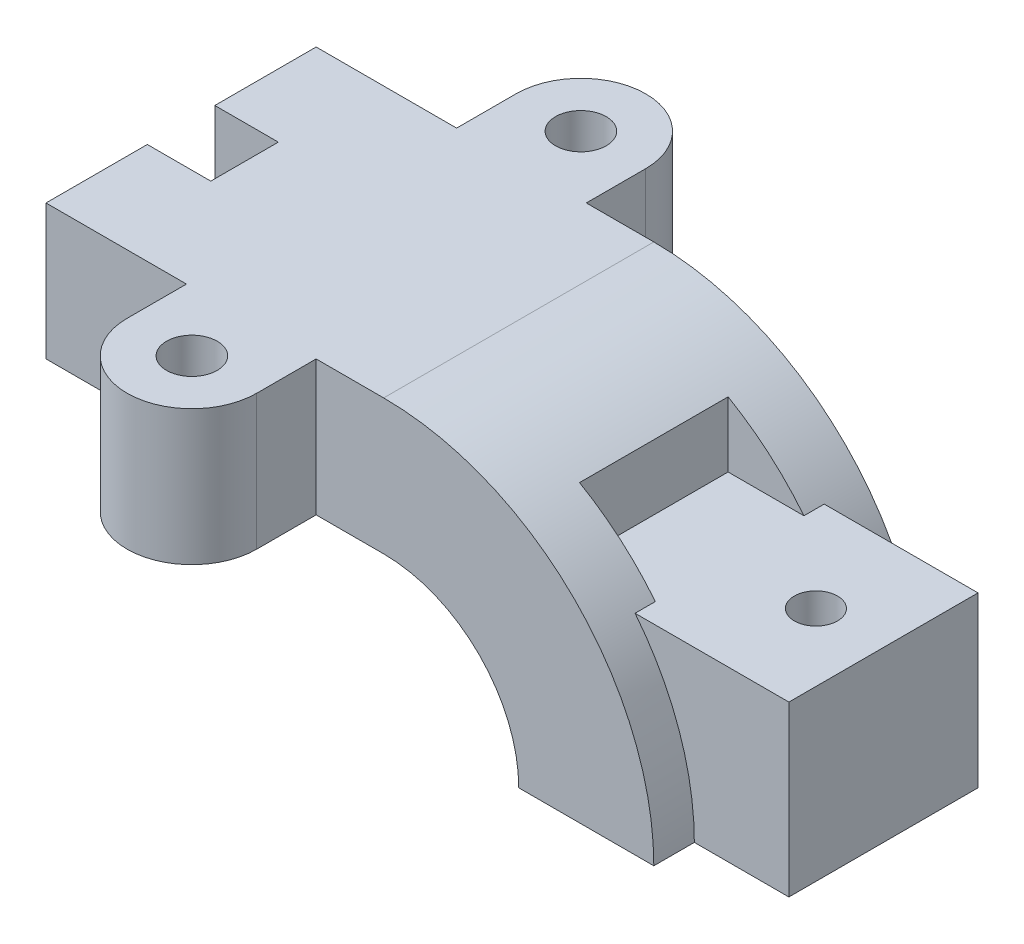
from build123d import *

# Parameters (mm, degrees)
BOSS_EXTRUDE1_DEPTH = 6.35
BOSS_EXTRUDE2_START = 6.35
SKETCH1_3_W         = 11.938
SKETCH1_3_H         = 19.05
SKETCH1_3_H_2       = 6.35
BOSS_EXTRUDE2_DEPTH = 7.62
BOSS_EXTRUDE3_START = 13.97
SKETCH1_7_W         = 11.938
SKETCH1_7_H         = 19.05
SKETCH1_7_H_2       = 6.35
BOSS_EXTRUDE3_DEPTH = 3.81
BOSS_EXTRUDE4_START = 17.78
SKETCH1_10_W        = 11.938
SKETCH1_10_H        = 6.35
SKETCH1_10_H_2      = 19.05
BOSS_EXTRUDE4_DEPTH = 7.62
SKETCH2_R           = 4.7625
BOSS_EXTRUDE5_DEPTH = 25.4
SKETCH3_R           = 4.064
CUT_EXTRUDE1_DEPTH  = 32.75


with BuildPart() as part:
    # Sketch1 → Boss-Extrude1 (new body)
    with BuildSketch(Plane.XY):
        with BuildLine():
            ThreePointArc((0, 25.4), (17.960512242, 17.960512242), (25.4, 0))
            Line((25.4, 0), (25.4, 31.75))
            Line((25.4, 31.75), (-51.562, 31.75))
            Line((-51.562, 31.75), (-51.562, 25.4))
            Line((-51.562, 25.4), (0, 25.4))
        make_face()
        with BuildLine():
            Line((-51.562, 31.75), (25.4, 31.75))
            Line((25.4, 31.75), (25.4, 43.994090512))
            ThreePointArc((25.4, 43.994090512), (13.148007491, 49.069031975), (0, 50.8))
            Line((0, 50.8), (-51.562, 50.8))
            Line((-51.562, 50.8), (-51.562, 31.75))
        make_face()
        with BuildLine():
            Line((25.4, 31.75), (25.4, 0))
            Line((25.4, 0), (50.8, 0))
            ThreePointArc((50.8, 0), (47.933033778, 16.824514045), (39.65573729, 31.75))
            Line((39.65573729, 31.75), (25.4, 31.75))
        make_face()
        with BuildLine():
            ThreePointArc((39.65573729, 31.75), (47.933033778, 16.824514045), (50.8, 0))
            Line((50.8, 0), (68.58, 0))
            Line((68.58, 0), (68.58, 31.75))
            Line((68.58, 31.75), (39.65573729, 31.75))
        make_face()
    boss_extrude1 = extrude(amount=BOSS_EXTRUDE1_DEPTH)

    # Sketch1_3 → Boss-Extrude2 (add)
    with BuildSketch(Plane.XY.offset(BOSS_EXTRUDE2_START)):
        with BuildLine():
            Line((-51.562, 31.75), (25.4, 31.75))
            Line((25.4, 31.75), (25.4, 43.994090512))
            ThreePointArc((25.4, 43.994090512), (13.148007491, 49.069031975), (0, 50.8))
            Line((0, 50.8), (-51.562, 50.8))
            Line((-51.562, 50.8), (-51.562, 31.75))
        make_face()
        with BuildLine():
            ThreePointArc((0, 25.4), (17.960512242, 17.960512242), (25.4, 0))
            Line((25.4, 0), (25.4, 31.75))
            Line((25.4, 31.75), (-51.562, 31.75))
            Line((-51.562, 31.75), (-51.562, 25.4))
            Line((-51.562, 25.4), (0, 25.4))
        make_face()
        with Locations((-57.531, 41.275)):
            Rectangle(SKETCH1_3_W, SKETCH1_3_H)
        with BuildLine():
            Line((25.4, 31.75), (25.4, 0))
            Line((25.4, 0), (50.8, 0))
            ThreePointArc((50.8, 0), (47.933033778, 16.824514045), (39.65573729, 31.75))
            Line((39.65573729, 31.75), (25.4, 31.75))
        make_face()
        with BuildLine():
            ThreePointArc((39.65573729, 31.75), (47.933033778, 16.824514045), (50.8, 0))
            Line((50.8, 0), (68.58, 0))
            Line((68.58, 0), (68.58, 31.75))
            Line((68.58, 31.75), (39.65573729, 31.75))
        make_face()
        with Locations((-57.531, 28.575)):
            Rectangle(SKETCH1_3_W, SKETCH1_3_H_2)
    boss_extrude2 = extrude(amount=BOSS_EXTRUDE2_DEPTH)

    # Sketch1_7 → Boss-Extrude3 (add)
    with BuildSketch(Plane.XY.offset(BOSS_EXTRUDE3_START)):
        with BuildLine():
            Line((-51.562, 31.75), (25.4, 31.75))
            Line((25.4, 31.75), (25.4, 43.994090512))
            ThreePointArc((25.4, 43.994090512), (13.148007491, 49.069031975), (0, 50.8))
            Line((0, 50.8), (-51.562, 50.8))
            Line((-51.562, 50.8), (-51.562, 31.75))
        make_face()
        with BuildLine():
            ThreePointArc((0, 25.4), (17.960512242, 17.960512242), (25.4, 0))
            Line((25.4, 0), (25.4, 31.75))
            Line((25.4, 31.75), (-51.562, 31.75))
            Line((-51.562, 31.75), (-51.562, 25.4))
            Line((-51.562, 25.4), (0, 25.4))
        make_face()
        with BuildLine():
            Line((25.4, 31.75), (25.4, 0))
            Line((25.4, 0), (50.8, 0))
            ThreePointArc((50.8, 0), (47.933033778, 16.824514045), (39.65573729, 31.75))
            Line((39.65573729, 31.75), (25.4, 31.75))
        make_face()
        with BuildLine():
            Line((25.4, 43.994090512), (25.4, 31.75))
            Line((25.4, 31.75), (39.65573729, 31.75))
            ThreePointArc((39.65573729, 31.75), (33.09896791, 38.536973458), (25.4, 43.994090512))
        make_face()
        with Locations((-57.531, 41.275)):
            Rectangle(SKETCH1_7_W, SKETCH1_7_H)
        with Locations((-57.531, 28.575)):
            Rectangle(SKETCH1_7_W, SKETCH1_7_H_2)
        with BuildLine():
            ThreePointArc((39.65573729, 31.75), (47.933033778, 16.824514045), (50.8, 0))
            Line((50.8, 0), (68.58, 0))
            Line((68.58, 0), (68.58, 31.75))
            Line((68.58, 31.75), (39.65573729, 31.75))
        make_face()
    boss_extrude3 = extrude(amount=BOSS_EXTRUDE3_DEPTH)

    # Sketch1_10 → Boss-Extrude4 (add)
    with BuildSketch(Plane.XY.offset(BOSS_EXTRUDE4_START)):
        with BuildLine():
            Line((-51.562, 31.75), (25.4, 31.75))
            Line((25.4, 31.75), (25.4, 43.994090512))
            ThreePointArc((25.4, 43.994090512), (13.148007491, 49.069031975), (0, 50.8))
            Line((0, 50.8), (-51.562, 50.8))
            Line((-51.562, 50.8), (-51.562, 31.75))
        make_face()
        with BuildLine():
            ThreePointArc((0, 25.4), (17.960512242, 17.960512242), (25.4, 0))
            Line((25.4, 0), (25.4, 31.75))
            Line((25.4, 31.75), (-51.562, 31.75))
            Line((-51.562, 31.75), (-51.562, 25.4))
            Line((-51.562, 25.4), (0, 25.4))
        make_face()
        with Locations((-57.531, 28.575)):
            Rectangle(SKETCH1_10_W, SKETCH1_10_H)
        with Locations((-57.531, 41.275)):
            Rectangle(SKETCH1_10_W, SKETCH1_10_H_2)
        with BuildLine():
            Line((25.4, 43.994090512), (25.4, 31.75))
            Line((25.4, 31.75), (39.65573729, 31.75))
            ThreePointArc((39.65573729, 31.75), (33.09896791, 38.536973458), (25.4, 43.994090512))
        make_face()
        with BuildLine():
            Line((25.4, 31.75), (25.4, 0))
            Line((25.4, 0), (50.8, 0))
            ThreePointArc((50.8, 0), (47.933033778, 16.824514045), (39.65573729, 31.75))
            Line((39.65573729, 31.75), (25.4, 31.75))
        make_face()
    boss_extrude4 = extrude(amount=BOSS_EXTRUDE4_DEPTH)

    # Mirror7: Boss-Extrude1, Boss-Extrude2, Boss-Extrude3, Boss-Extrude4 across plane
    add(boss_extrude1.mirror(Plane.XY))
    add(boss_extrude2.mirror(Plane.XY))
    add(boss_extrude3.mirror(Plane.XY))
    add(boss_extrude4.mirror(Plane.XY))

    # Sketch2 → Boss-Extrude5 (add)
    with BuildSketch(Plane(origin=(0, 50.8, 0), x_dir=(1, 0, 0), z_dir=(0, 1, 0))):
        with BuildLine():
            Line((-12.7, 25.4), (-12.7, 36.576))
            ThreePointArc((-12.7, 36.576), (-24.892, 48.768), (-37.084, 36.576))
            Line((-37.084, 36.576), (-37.084, 25.4))
            Line((-37.084, 25.4), (-12.7, 25.4))
        make_face()
        with Locations((-24.892, 36.576)):
            Circle(SKETCH2_R, mode=Mode.SUBTRACT)
        with BuildLine():
            Line((-37.084, -25.4), (-37.084, -36.576))
            ThreePointArc((-37.084, -36.576), (-24.892, -48.768), (-12.7, -36.576))
            Line((-12.7, -36.576), (-12.7, -25.4))
            Line((-12.7, -25.4), (-37.084, -25.4))
        make_face()
        with Locations((-24.892, -36.576)):
            Circle(SKETCH2_R, mode=Mode.SUBTRACT)
    extrude(amount=-BOSS_EXTRUDE5_DEPTH)

    # Sketch3 → Cut-Extrude1 (cut, through all)
    with BuildSketch(Plane(origin=(0, 31.75, 0), x_dir=(1, 0, 0), z_dir=(0, 1, 0))):
        with Locations((55.88, 0)):
            Circle(SKETCH3_R)
    extrude(amount=-CUT_EXTRUDE1_DEPTH, mode=Mode.SUBTRACT)


solid = part.part
